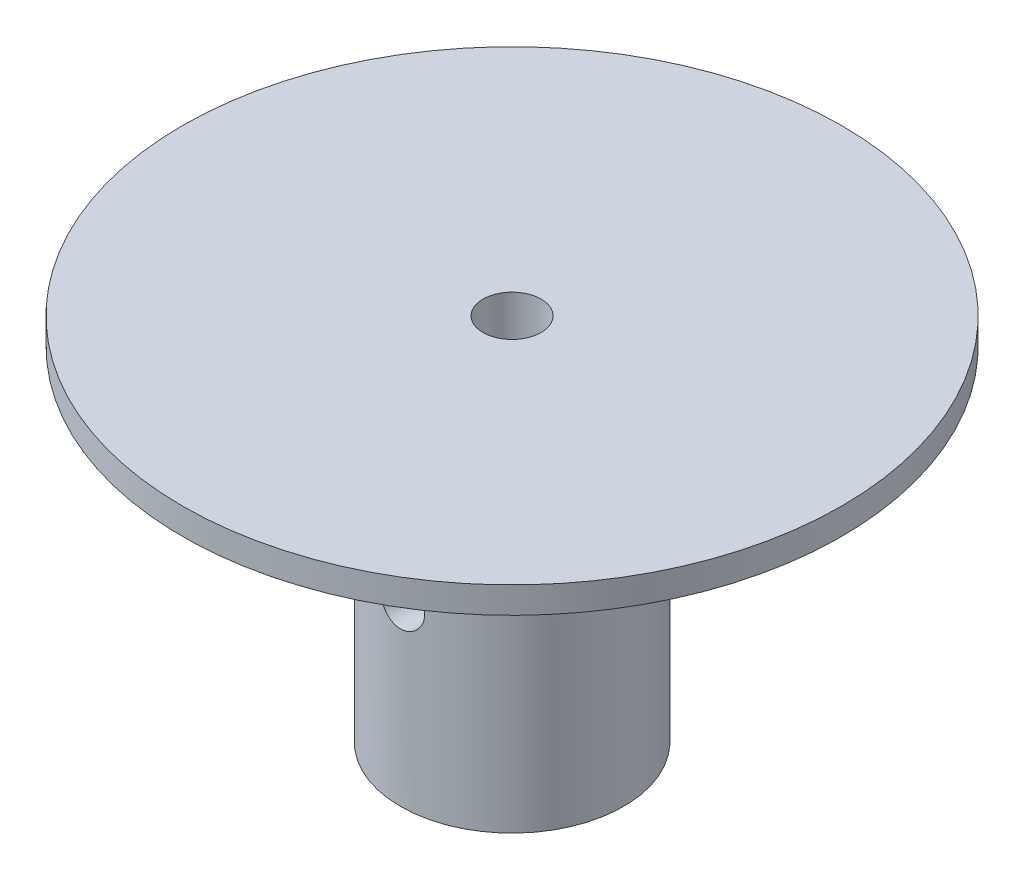
from build123d import *

# Parameters (mm, degrees)
SKETCH1_R               = 12.7
BOSS_EXTRUDE1_DEPTH     = 40
SKETCH2_R               = 37.5
BOSS_EXTRUDE2_DEPTH     = 2
SKETCH3_R               = 3.302
CUT_EXTRUDE1_DEPTH      = 43
SKETCH4_R               = 2.5
CUT_EXTRUDE2_DEPTH      = 38.5
CUT_EXTRUDE2_DEPTH_BACK = 38.5
SKETCH5_R               = 37.5
SKETCH5_R_2             = 12.7
BOSS_EXTRUDE3_DEPTH     = 1


with BuildPart() as part:
    # Sketch1 → Boss-Extrude1 (new body)
    with BuildSketch(Plane(origin=(0, 0, 0), x_dir=(1, 0, 0), z_dir=(0, 1, 0))):
        Circle(SKETCH1_R)
    extrude(amount=BOSS_EXTRUDE1_DEPTH)

    # Sketch2 → Boss-Extrude2 (add)
    with BuildSketch(Plane(origin=(0, 40, 0), x_dir=(1, 0, 0), z_dir=(0, 1, 0))):
        Circle(SKETCH2_R)
    extrude(amount=BOSS_EXTRUDE2_DEPTH)

    # Sketch3 → Cut-Extrude1 (cut, through all)
    with BuildSketch(Plane(origin=(0, 0, 0), x_dir=(-1, 0, 0), z_dir=(0, -1, 0))):
        Circle(SKETCH3_R)
    extrude(amount=-CUT_EXTRUDE1_DEPTH, mode=Mode.SUBTRACT)

    # Sketch4 → Cut-Extrude2 (cut, two sides)
    with BuildSketch(Plane.XY) as cut_extrude2_sk:
        with Locations((0, 20)):
            Circle(SKETCH4_R)
    extrude(amount=CUT_EXTRUDE2_DEPTH, mode=Mode.SUBTRACT)
    extrude(cut_extrude2_sk.sketch, amount=-CUT_EXTRUDE2_DEPTH_BACK, mode=Mode.SUBTRACT)

    # Sketch5 → Boss-Extrude3 (add)
    with BuildSketch(Plane.XZ.offset(-40)):
        Circle(SKETCH5_R)
        Circle(SKETCH5_R_2, mode=Mode.SUBTRACT)
    extrude(amount=BOSS_EXTRUDE3_DEPTH)


solid = part.part
